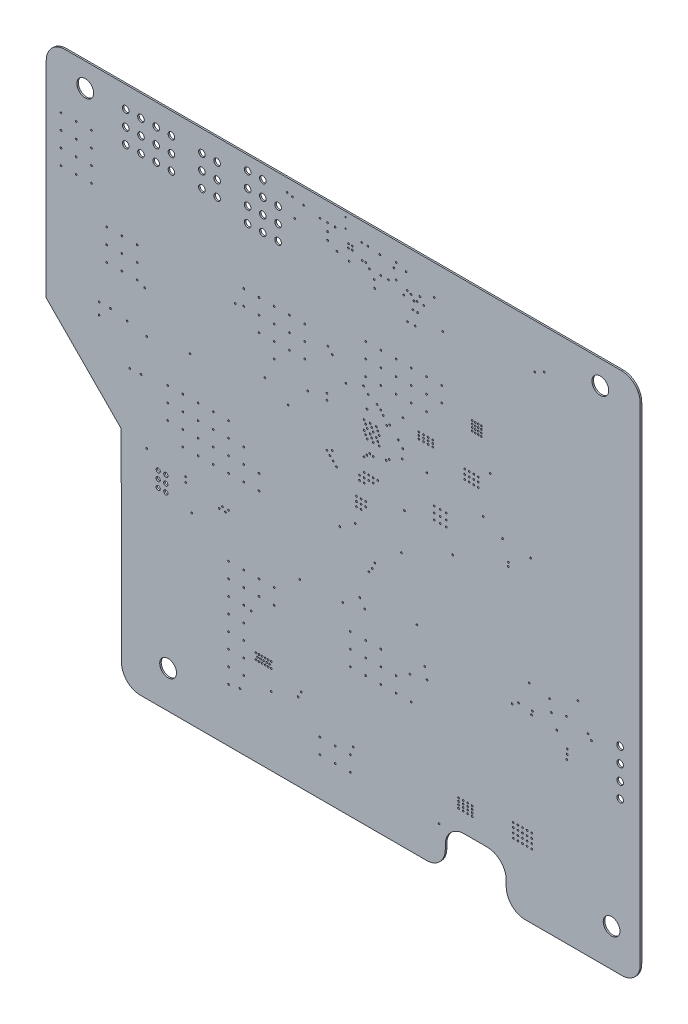
from build123d import *

# Parameters (mm, degrees)
BOARD_OUTLINE_START = 0.034
BOARD_OUTLINE_DEPTH = 0.254
SKETCH2_R           = 0.1395
SKETCH2_R_2         = 0.1015
VIA_DEPTH           = 1.288
SKETCH3_R           = 1.397
NPTH_DEPTH          = 1.288
SKETCH4_R           = 0.55
SKETCH4_R_2         = 0.35
SKETCH4_R_3         = 0.1395
PTH_DEPTH           = 1.288


with BuildPart() as part:
    # Sketch1 → Board_Outline (new body)
    with BuildSketch(Plane.XY.offset(BOARD_OUTLINE_START)):
        with BuildLine():
            Line((48.336, -41.631), (48.336, 39.37))
            ThreePointArc((48.336, 39.37), (47.424377843, 41.607667406), (45.187, 42.52))
            Line((45.187, 42.52), (-47.549, 42.52))
            ThreePointArc((-47.549, 42.52), (-49.791303069, 41.604999919), (-50.724, 39.37))
            Line((-50.724, 39.37), (-50.724, 5.055))
            Line((-50.724, 5.055), (-38.227, -7.569))
            Line((-38.227, -7.569), (-38.176, -41.3))
            ThreePointArc((-38.176, -41.3), (-37.255008626, -43.554008626), (-35.001, -44.475))
            Line((-35.001, -44.475), (12.7, -44.475))
            ThreePointArc((12.7, -44.475), (14.932114941, -43.529199711), (15.824, -41.275))
            Line((15.824, -41.275), (15.824, -40.615))
            ThreePointArc((15.824, -40.615), (16.739034543, -38.423313296), (18.923, -37.49))
            Line((18.923, -37.49), (22.835, -37.49))
            ThreePointArc((22.835, -37.49), (25.048735627, -38.408355043), (25.984, -40.615))
            Line((25.984, -40.615), (25.984, -41.631))
            ThreePointArc((25.984, -41.631), (26.914747345, -43.875252655), (29.159, -44.806))
            Line((29.159, -44.806), (45.11, -44.806))
            ThreePointArc((45.11, -44.806), (47.42069009, -43.927397081), (48.336, -41.631))
        make_face()
    extrude(amount=BOARD_OUTLINE_DEPTH)

    # Sketch2 → Via (cut, through all)
    with BuildSketch(Plane.XY):
        with Locations((-14.249, 11.76)):
            Circle(SKETCH2_R)
        with Locations((-10.388, 9.755)):
            Circle(SKETCH2_R)
        with Locations((-3.912, 13.691)):
            Circle(SKETCH2_R)
        with Locations((-2.311, 4.851)):
            Circle(SKETCH2_R)
        with Locations((-3.912, 14.681)):
            Circle(SKETCH2_R)
        with Locations((-3.912, 6.452)):
            Circle(SKETCH2_R)
        with Locations((-8.433, -14.478)):
            Circle(SKETCH2_R)
        with Locations((39.624, -12.7)):
            Circle(SKETCH2_R)
        with Locations((-7.806, 39.916)):
            Circle(SKETCH2_R)
        with Locations((-27.457, -9.957)):
            Circle(SKETCH2_R)
        with Locations((-27.483, -9.144)):
            Circle(SKETCH2_R)
        with Locations((-26.746, 8.992)):
            Circle(SKETCH2_R)
        with Locations((12.751, 11.532)):
            Circle(SKETCH2_R)
        with Locations((11.1, -11.252)):
            Circle(SKETCH2_R)
        with Locations((3.632, -6.858)):
            Circle(SKETCH2_R)
        with Locations((12.776, -18.364)):
            Circle(SKETCH2_R)
        with Locations((12.395, -16.612)):
            Circle(SKETCH2_R)
        with Locations((4.089, -5.817)):
            Circle(SKETCH2_R)
        with Locations((9.931, -18.974)):
            Circle(SKETCH2_R)
        with Locations((3.099, -7.595)):
            Circle(SKETCH2_R)
        with Locations((-1.753, -3.505)):
            Circle(SKETCH2_R)
        with Locations((-7.137, 13.411)):
            Circle(SKETCH2_R)
        with Locations((5.486, 16.18)):
            Circle(SKETCH2_R)
        with Locations((25.375, 8.357)):
            Circle(SKETCH2_R)
        with Locations((5.08, 16.764)):
            Circle(SKETCH2_R)
        with Locations((26.365, 5.41)):
            Circle(SKETCH2_R)
        with Locations((22.149, 9.931)):
            Circle(SKETCH2_R)
        with Locations((6.045, 15.011)):
            Circle(SKETCH2_R)
        with Locations((-3.023, 6.883)):
            Circle(SKETCH2_R)
        with Locations((-3.023, 20.701)):
            Circle(SKETCH2_R)
        with Locations((2.184, 18.796)):
            Circle(SKETCH2_R)
        with Locations((8.763, 17.475)):
            Circle(SKETCH2_R)
        with Locations((6.553, 15.367)):
            Circle(SKETCH2_R)
        with Locations((8.001, 13.919)):
            Circle(SKETCH2_R)
        with Locations((4.445, 17.247)):
            Circle(SKETCH2_R)
        with Locations((26.314, 4.775)):
            Circle(SKETCH2_R)
        with Locations((17.069, 1.854)):
            Circle(SKETCH2_R)
        with Locations((8.636, 11.481)):
            Circle(SKETCH2_R)
        with Locations((33.528, -12.7)):
            Circle(SKETCH2_R)
        with Locations((14.783, -38.125)):
            Circle(SKETCH2_R)
        with Locations((-33.964, -8.331)):
            Circle(SKETCH2_R)
        with Locations((-33.964, 7.844)):
            Circle(SKETCH2_R)
        with Locations((-19.177, 20.015)):
            Circle(SKETCH2_R)
        with Locations((-9.296, 37.236)):
            Circle(SKETCH2_R)
        with Locations((15.391, 33.271)):
            Circle(SKETCH2_R)
        with Locations((10.109, 35.972)):
            Circle(SKETCH2_R)
        with Locations((-26.441, -13.868)):
            Circle(SKETCH2_R)
        with Locations((2.972, 17.932)):
            Circle(SKETCH2_R)
        with Locations((23.317, 16.713)):
            Circle(SKETCH2_R)
        with Locations((2.769, 15.748)):
            Circle(SKETCH2_R)
        with Locations((0.813, -1.778)):
            Circle(SKETCH2_R)
        with Locations((30.048, 7.874)):
            Circle(SKETCH2_R)
        with Locations((8.738, 13.005)):
            Circle(SKETCH2_R)
        with Locations((-0.762, 17.704)):
            Circle(SKETCH2_R)
        with Locations((3.81, 9.398)):
            Circle(SKETCH2_R)
        with Locations((9.017, 4.216)):
            Circle(SKETCH2_R)
        with Locations((8.509, -2.134)):
            Circle(SKETCH2_R)
        with Locations((-0.808, 40.012)):
            Circle(SKETCH2_R_2)
        with Locations((-0.808, 41.686)):
            Circle(SKETCH2_R_2)
        with Locations((36.144, -17.424)):
            Circle(SKETCH2_R)
        with Locations((33.223, -10.846)):
            Circle(SKETCH2_R)
        with Locations((36.081, -18.199)):
            Circle(SKETCH2_R)
        with Locations((29.82, -10.287)):
            Circle(SKETCH2_R)
        with Locations((2.388, -13.326)):
            Circle(SKETCH2_R)
        with Locations((1.575, -12.09)):
            Circle(SKETCH2_R)
        with Locations((-36.779, 1.829)):
            Circle(SKETCH2_R)
        with Locations((-37.233, 8.455)):
            Circle(SKETCH2_R)
        with Locations((2.261, 8.585)):
            Circle(SKETCH2_R)
        with Locations((2.743, 9.068)):
            Circle(SKETCH2_R)
        with Locations((3.251, 9.55)):
            Circle(SKETCH2_R)
        with Locations((30.365, -14.06)):
            Circle(SKETCH2_R)
        with Locations((28.042, -14.06)):
            Circle(SKETCH2_R)
        with Locations((30.201, -14.707)):
            Circle(SKETCH2_R)
        with Locations((26.975, -14.707)):
            Circle(SKETCH2_R)
        with Locations((37.948, -8.788)):
            Circle(SKETCH2_R)
        with Locations((36.195, -16.637)):
            Circle(SKETCH2_R)
        with Locations((34.417, -14.808)):
            Circle(SKETCH2_R)
        with Locations((-8.179, -30.607)):
            Circle(SKETCH2_R)
        with Locations((-18.415, -35.204)):
            Circle(SKETCH2_R)
        with Locations((-1.27, -14.224)):
            Circle(SKETCH2_R)
        with Locations((-16.561, -23.063)):
            Circle(SKETCH2_R)
        with Locations((-8.712, -31.547)):
            Circle(SKETCH2_R)
        with Locations((0.457, -34.214)):
            Circle(SKETCH2_R)
        with Locations((-13.183, -33.02)):
            Circle(SKETCH2_R)
        with Locations((-34.315, 14.732)):
            Circle(SKETCH2_R)
        with Locations((-3.734, 21.565)):
            Circle(SKETCH2_R)
        with Locations((4.039, 33.833)):
            Circle(SKETCH2_R)
        with Locations((9.474, 36.246)):
            Circle(SKETCH2_R)
        with Locations((11.609, 36.424)):
            Circle(SKETCH2_R)
        with Locations((1.981, 36.818)):
            Circle(SKETCH2_R)
        with Locations((-0.212, 35.611)):
            Circle(SKETCH2_R)
        with Locations((-2.235, 36.017)):
            Circle(SKETCH2_R)
        with Locations((7.264, 38.379)):
            Circle(SKETCH2_R)
        with Locations((13.97, 37.465)):
            Circle(SKETCH2_R)
        with Locations((12.243, 35.458)):
            Circle(SKETCH2_R)
        with Locations((11.125, 35.458)):
            Circle(SKETCH2_R)
        with Locations((3.962, 35.077)):
            Circle(SKETCH2_R)
        with Locations((4.927, 39.129)):
            Circle(SKETCH2_R)
        with Locations((1.88, 39.345)):
            Circle(SKETCH2_R)
        with Locations((2.921, 39.345)):
            Circle(SKETCH2_R)
        with Locations((9.296, 38.862)):
            Circle(SKETCH2_R)
        with Locations((36.043, -11.989)):
            Circle(SKETCH2_R)
        with Locations((10.609, 35.281)):
            Circle(SKETCH2_R)
        with Locations((8.89, 35.281)):
            Circle(SKETCH2_R)
        with Locations((5.969, 9.957)):
            Circle(SKETCH2_R)
        with Locations((-10.542, 40.352)):
            Circle(SKETCH2_R)
        with Locations((32.317, 35.873)):
            Circle(SKETCH2_R)
        with Locations((30.74, 35.064)):
            Circle(SKETCH2_R)
        with Locations((6.502, 10.312)):
            Circle(SKETCH2_R)
        with Locations((-9.666, 40.178)):
            Circle(SKETCH2_R)
    extrude(amount=VIA_DEPTH, mode=Mode.SUBTRACT)

    # Sketch3 → NPTH (cut, through all)
    with BuildSketch(Plane.XY):
        with Locations((41.681, 38.583)):
            Circle(SKETCH3_R)
        with Locations((-44.221, 38.583)):
            Circle(SKETCH3_R)
        with Locations((-30.404, -38.252)):
            Circle(SKETCH3_R)
        with Locations((43.561, -38.557)):
            Circle(SKETCH3_R)
    extrude(amount=NPTH_DEPTH, mode=Mode.SUBTRACT)

    # Sketch4 → PTH (cut, through all)
    with BuildSketch(Plane.XY):
        with Locations((-22.225, 33.833)):
            Circle(SKETCH4_R)
        with Locations((-24.765, 33.833)):
            Circle(SKETCH4_R)
        with Locations((-22.225, 36.373)):
            Circle(SKETCH4_R)
        with Locations((-24.765, 36.373)):
            Circle(SKETCH4_R)
        with Locations((-22.225, 38.913)):
            Circle(SKETCH4_R)
        with Locations((-24.765, 38.913)):
            Circle(SKETCH4_R)
        with Locations((-14.605, 32.563)):
            Circle(SKETCH4_R)
        with Locations((-17.145, 32.563)):
            Circle(SKETCH4_R)
        with Locations((-14.605, 35.103)):
            Circle(SKETCH4_R)
        with Locations((-17.145, 35.103)):
            Circle(SKETCH4_R)
        with Locations((-14.605, 37.643)):
            Circle(SKETCH4_R)
        with Locations((-17.145, 37.643)):
            Circle(SKETCH4_R)
        with Locations((-14.605, 40.183)):
            Circle(SKETCH4_R)
        with Locations((-17.145, 40.183)):
            Circle(SKETCH4_R)
        with Locations((-29.845, 38.913)):
            Circle(SKETCH4_R)
        with Locations((-32.385, 38.913)):
            Circle(SKETCH4_R)
        with Locations((-34.925, 38.913)):
            Circle(SKETCH4_R)
        with Locations((-37.465, 38.913)):
            Circle(SKETCH4_R)
        with Locations((-29.845, 36.347)):
            Circle(SKETCH4_R)
        with Locations((-32.385, 36.347)):
            Circle(SKETCH4_R)
        with Locations((-34.925, 36.347)):
            Circle(SKETCH4_R)
        with Locations((-37.465, 36.347)):
            Circle(SKETCH4_R)
        with Locations((-29.845, 33.807)):
            Circle(SKETCH4_R)
        with Locations((-32.385, 33.807)):
            Circle(SKETCH4_R)
        with Locations((-34.925, 33.807)):
            Circle(SKETCH4_R)
        with Locations((-37.465, 33.807)):
            Circle(SKETCH4_R)
        with Locations((44.983, -19.456)):
            Circle(SKETCH4_R)
        with Locations((44.983, -16.916)):
            Circle(SKETCH4_R)
        with Locations((44.983, -14.376)):
            Circle(SKETCH4_R)
        with Locations((44.983, -11.836)):
            Circle(SKETCH4_R)
        with Locations((-30.785, -13.056)):
            Circle(SKETCH4_R_2)
        with Locations((-30.785, -11.786)):
            Circle(SKETCH4_R_2)
        with Locations((-30.785, -10.516)):
            Circle(SKETCH4_R_2)
        with Locations((-32.055, -13.056)):
            Circle(SKETCH4_R_2)
        with Locations((-32.055, -11.786)):
            Circle(SKETCH4_R_2)
        with Locations((-32.055, -10.516)):
            Circle(SKETCH4_R_2)
        with Locations((-12.065, 32.563)):
            Circle(SKETCH4_R)
        with Locations((-12.065, 35.103)):
            Circle(SKETCH4_R)
        with Locations((-12.065, 37.643)):
            Circle(SKETCH4_R)
        with Locations((1.016, 2.286)):
            Circle(SKETCH4_R_3)
        with Locations((1.778, 2.286)):
            Circle(SKETCH4_R_3)
        with Locations((1.778, 1.524)):
            Circle(SKETCH4_R_3)
        with Locations((1.016, 1.524)):
            Circle(SKETCH4_R_3)
        with Locations((1.016, 0.762)):
            Circle(SKETCH4_R_3)
        with Locations((1.778, 0.762)):
            Circle(SKETCH4_R_3)
        with Locations((2.54, 2.286)):
            Circle(SKETCH4_R_3)
        with Locations((2.54, 1.524)):
            Circle(SKETCH4_R_3)
        with Locations((13.97, 7.366)):
            Circle(SKETCH4_R_3)
        with Locations((14.986, 7.366)):
            Circle(SKETCH4_R_3)
        with Locations((16.002, 7.366)):
            Circle(SKETCH4_R_3)
        with Locations((16.002, 6.35)):
            Circle(SKETCH4_R_3)
        with Locations((16.002, 5.334)):
            Circle(SKETCH4_R_3)
        with Locations((14.986, 6.35)):
            Circle(SKETCH4_R_3)
        with Locations((13.97, 6.35)):
            Circle(SKETCH4_R_3)
        with Locations((13.97, 5.334)):
            Circle(SKETCH4_R_3)
        with Locations((14.986, 5.334)):
            Circle(SKETCH4_R_3)
        with Locations((2.286, 13.97)):
            Circle(SKETCH4_R_3)
        with Locations((3.302, 13.97)):
            Circle(SKETCH4_R_3)
        with Locations((2.794, 12.954)):
            Circle(SKETCH4_R_3)
        with Locations((3.81, 12.954)):
            Circle(SKETCH4_R_3)
        with Locations((4.318, 13.97)):
            Circle(SKETCH4_R_3)
        with Locations((4.826, 12.954)):
            Circle(SKETCH4_R_3)
        with Locations((2.54, 13.462)):
            Circle(SKETCH4_R_3)
        with Locations((3.556, 13.462)):
            Circle(SKETCH4_R_3)
        with Locations((2.286, 12.446)):
            Circle(SKETCH4_R_3)
        with Locations((2.54, 11.938)):
            Circle(SKETCH4_R_3)
        with Locations((4.572, 13.462)):
            Circle(SKETCH4_R_3)
        with Locations((2.794, 11.43)):
            Circle(SKETCH4_R_3)
        with Locations((3.302, 12.446)):
            Circle(SKETCH4_R_3)
        with Locations((3.556, 11.938)):
            Circle(SKETCH4_R_3)
        with Locations((3.81, 11.43)):
            Circle(SKETCH4_R_3)
        with Locations((4.318, 12.446)):
            Circle(SKETCH4_R_3)
        with Locations((4.572, 11.938)):
            Circle(SKETCH4_R_3)
        with Locations((4.826, 11.43)):
            Circle(SKETCH4_R_3)
        with Locations((4.572, 6.35)):
            Circle(SKETCH4_R_3)
        with Locations((2.286, 6.35)):
            Circle(SKETCH4_R_3)
        with Locations((3.048, 6.35)):
            Circle(SKETCH4_R_3)
        with Locations((3.81, 6.35)):
            Circle(SKETCH4_R_3)
        with Locations((2.286, 5.588)):
            Circle(SKETCH4_R_3)
        with Locations((3.048, 5.588)):
            Circle(SKETCH4_R_3)
        with Locations((2.286, 4.826)):
            Circle(SKETCH4_R_3)
        with Locations((1.524, 5.588)):
            Circle(SKETCH4_R_3)
        with Locations((1.524, 4.826)):
            Circle(SKETCH4_R_3)
        with Locations((3.81, 5.588)):
            Circle(SKETCH4_R_3)
        with Locations((-15.748, -28.702)):
            Circle(SKETCH4_R_3)
        with Locations((-15.24, -28.702)):
            Circle(SKETCH4_R_3)
        with Locations((-14.732, -28.702)):
            Circle(SKETCH4_R_3)
        with Locations((-14.224, -28.702)):
            Circle(SKETCH4_R_3)
        with Locations((-13.716, -28.702)):
            Circle(SKETCH4_R_3)
        with Locations((-13.208, -28.702)):
            Circle(SKETCH4_R_3)
        with Locations((-15.494, -29.21)):
            Circle(SKETCH4_R_3)
        with Locations((-14.986, -29.21)):
            Circle(SKETCH4_R_3)
        with Locations((-14.478, -29.21)):
            Circle(SKETCH4_R_3)
        with Locations((-13.97, -29.21)):
            Circle(SKETCH4_R_3)
        with Locations((-13.462, -29.21)):
            Circle(SKETCH4_R_3)
        with Locations((-15.24, -29.718)):
            Circle(SKETCH4_R_3)
        with Locations((-14.732, -29.718)):
            Circle(SKETCH4_R_3)
        with Locations((-14.224, -29.718)):
            Circle(SKETCH4_R_3)
        with Locations((-13.716, -29.718)):
            Circle(SKETCH4_R_3)
        with Locations((-13.208, -29.718)):
            Circle(SKETCH4_R_3)
        with Locations((-15.748, -29.718)):
            Circle(SKETCH4_R_3)
        with Locations((-3.912, 14.681)):
            Circle(SKETCH4_R_3)
        with Locations((-2.87, 5.41)):
            Circle(SKETCH4_R_3)
        with Locations((-3.404, 5.944)):
            Circle(SKETCH4_R_3)
        with Locations((-30.48, 2.54)):
            Circle(SKETCH4_R_3)
        with Locations((20.32, 22.86)):
            Circle(SKETCH4_R_3)
        with Locations((20.32, 22.352)):
            Circle(SKETCH4_R_3)
        with Locations((20.32, 21.844)):
            Circle(SKETCH4_R_3)
        with Locations((20.32, 21.336)):
            Circle(SKETCH4_R_3)
        with Locations((20.828, 22.86)):
            Circle(SKETCH4_R_3)
        with Locations((20.828, 22.352)):
            Circle(SKETCH4_R_3)
        with Locations((20.828, 21.844)):
            Circle(SKETCH4_R_3)
        with Locations((20.828, 21.336)):
            Circle(SKETCH4_R_3)
        with Locations((21.336, 22.86)):
            Circle(SKETCH4_R_3)
        with Locations((21.336, 22.352)):
            Circle(SKETCH4_R_3)
        with Locations((21.336, 21.844)):
            Circle(SKETCH4_R_3)
        with Locations((21.336, 21.336)):
            Circle(SKETCH4_R_3)
        with Locations((21.844, 22.86)):
            Circle(SKETCH4_R_3)
        with Locations((21.844, 22.352)):
            Circle(SKETCH4_R_3)
        with Locations((21.844, 21.844)):
            Circle(SKETCH4_R_3)
        with Locations((21.844, 21.336)):
            Circle(SKETCH4_R_3)
        with Locations((18.034, -32.766)):
            Circle(SKETCH4_R_3)
        with Locations((18.796, -32.766)):
            Circle(SKETCH4_R_3)
        with Locations((19.558, -32.766)):
            Circle(SKETCH4_R_3)
        with Locations((20.32, -32.766)):
            Circle(SKETCH4_R_3)
        with Locations((20.32, -33.274)):
            Circle(SKETCH4_R_3)
        with Locations((19.558, -33.274)):
            Circle(SKETCH4_R_3)
        with Locations((18.796, -33.274)):
            Circle(SKETCH4_R_3)
        with Locations((18.034, -33.274)):
            Circle(SKETCH4_R_3)
        with Locations((18.034, -33.782)):
            Circle(SKETCH4_R_3)
        with Locations((18.796, -33.782)):
            Circle(SKETCH4_R_3)
        with Locations((19.558, -33.782)):
            Circle(SKETCH4_R_3)
        with Locations((20.32, -33.782)):
            Circle(SKETCH4_R_3)
        with Locations((20.32, -34.29)):
            Circle(SKETCH4_R_3)
        with Locations((19.558, -34.29)):
            Circle(SKETCH4_R_3)
        with Locations((18.796, -34.29)):
            Circle(SKETCH4_R_3)
        with Locations((18.034, -34.29)):
            Circle(SKETCH4_R_3)
        with Locations((27.178, -31.75)):
            Circle(SKETCH4_R_3)
        with Locations((27.94, -31.75)):
            Circle(SKETCH4_R_3)
        with Locations((28.702, -31.75)):
            Circle(SKETCH4_R_3)
        with Locations((29.464, -31.75)):
            Circle(SKETCH4_R_3)
        with Locations((30.226, -31.75)):
            Circle(SKETCH4_R_3)
        with Locations((29.464, -32.512)):
            Circle(SKETCH4_R_3)
        with Locations((30.226, -32.512)):
            Circle(SKETCH4_R_3)
        with Locations((28.702, -32.512)):
            Circle(SKETCH4_R_3)
        with Locations((27.94, -32.512)):
            Circle(SKETCH4_R_3)
        with Locations((27.178, -32.512)):
            Circle(SKETCH4_R_3)
        with Locations((27.178, -33.274)):
            Circle(SKETCH4_R_3)
        with Locations((27.94, -33.274)):
            Circle(SKETCH4_R_3)
        with Locations((28.702, -33.274)):
            Circle(SKETCH4_R_3)
        with Locations((29.464, -33.274)):
            Circle(SKETCH4_R_3)
        with Locations((30.226, -33.274)):
            Circle(SKETCH4_R_3)
        with Locations((30.226, -34.036)):
            Circle(SKETCH4_R_3)
        with Locations((29.464, -34.036)):
            Circle(SKETCH4_R_3)
        with Locations((28.702, -34.036)):
            Circle(SKETCH4_R_3)
        with Locations((27.94, -34.036)):
            Circle(SKETCH4_R_3)
        with Locations((27.178, -34.036)):
            Circle(SKETCH4_R_3)
        with Locations((11.43, 16.764)):
            Circle(SKETCH4_R_3)
        with Locations((12.192, 16.764)):
            Circle(SKETCH4_R_3)
        with Locations((12.954, 16.764)):
            Circle(SKETCH4_R_3)
        with Locations((13.716, 16.764)):
            Circle(SKETCH4_R_3)
        with Locations((11.43, 16.256)):
            Circle(SKETCH4_R_3)
        with Locations((12.192, 16.256)):
            Circle(SKETCH4_R_3)
        with Locations((12.954, 16.256)):
            Circle(SKETCH4_R_3)
        with Locations((13.716, 16.256)):
            Circle(SKETCH4_R_3)
        with Locations((13.716, 15.748)):
            Circle(SKETCH4_R_3)
        with Locations((12.954, 15.748)):
            Circle(SKETCH4_R_3)
        with Locations((12.192, 15.748)):
            Circle(SKETCH4_R_3)
        with Locations((11.43, 15.748)):
            Circle(SKETCH4_R_3)
        with Locations((-21.336, -10.414)):
            Circle(SKETCH4_R_3)
        with Locations((-20.32, -10.414)):
            Circle(SKETCH4_R_3)
        with Locations((-20.828, -10.922)):
            Circle(SKETCH4_R_3)
        with Locations((-21.844, -10.922)):
            Circle(SKETCH4_R_3)
        with Locations((-20.32, -17.78)):
            Circle(SKETCH4_R_3)
        with Locations((-17.78, -17.78)):
            Circle(SKETCH4_R_3)
        with Locations((-15.24, -17.78)):
            Circle(SKETCH4_R_3)
        with Locations((-12.7, -17.78)):
            Circle(SKETCH4_R_3)
        with Locations((-12.7, -20.32)):
            Circle(SKETCH4_R_3)
        with Locations((-15.24, -20.32)):
            Circle(SKETCH4_R_3)
        with Locations((-17.78, -20.32)):
            Circle(SKETCH4_R_3)
        with Locations((-20.32, -20.32)):
            Circle(SKETCH4_R_3)
        with Locations((-20.32, -22.86)):
            Circle(SKETCH4_R_3)
        with Locations((-17.78, -22.86)):
            Circle(SKETCH4_R_3)
        with Locations((-17.78, -25.4)):
            Circle(SKETCH4_R_3)
        with Locations((-20.32, -25.4)):
            Circle(SKETCH4_R_3)
        with Locations((-17.78, -27.94)):
            Circle(SKETCH4_R_3)
        with Locations((-20.32, -27.94)):
            Circle(SKETCH4_R_3)
        with Locations((-17.78, -30.48)):
            Circle(SKETCH4_R_3)
        with Locations((-20.32, -30.48)):
            Circle(SKETCH4_R_3)
        with Locations((-17.78, -33.02)):
            Circle(SKETCH4_R_3)
        with Locations((-20.32, -33.02)):
            Circle(SKETCH4_R_3)
        with Locations((-20.32, -35.56)):
            Circle(SKETCH4_R_3)
        with Locations((0, -17.78)):
            Circle(SKETCH4_R_3)
        with Locations((2.54, -17.78)):
            Circle(SKETCH4_R_3)
        with Locations((5.08, -17.78)):
            Circle(SKETCH4_R_3)
        with Locations((5.08, -20.32)):
            Circle(SKETCH4_R_3)
        with Locations((2.54, -20.32)):
            Circle(SKETCH4_R_3)
        with Locations((0, -20.32)):
            Circle(SKETCH4_R_3)
        with Locations((0, -22.86)):
            Circle(SKETCH4_R_3)
        with Locations((2.54, -22.86)):
            Circle(SKETCH4_R_3)
        with Locations((5.08, -22.86)):
            Circle(SKETCH4_R_3)
        with Locations((7.62, -22.86)):
            Circle(SKETCH4_R_3)
        with Locations((7.62, -20.32)):
            Circle(SKETCH4_R_3)
        with Locations((10.16, -22.86)):
            Circle(SKETCH4_R_3)
        with Locations((0, -38.1)):
            Circle(SKETCH4_R_3)
        with Locations((-2.54, -38.1)):
            Circle(SKETCH4_R_3)
        with Locations((-5.08, -38.1)):
            Circle(SKETCH4_R_3)
        with Locations((-5.08, -35.56)):
            Circle(SKETCH4_R_3)
        with Locations((-2.54, -35.56)):
            Circle(SKETCH4_R_3)
        with Locations((0, -35.56)):
            Circle(SKETCH4_R_3)
        with Locations((2.54, 20.32)):
            Circle(SKETCH4_R_3)
        with Locations((-15.24, 17.78)):
            Circle(SKETCH4_R_3)
        with Locations((19.05, 15.24)):
            Circle(SKETCH4_R_3)
        with Locations((19.05, 14.478)):
            Circle(SKETCH4_R_3)
        with Locations((19.05, 13.716)):
            Circle(SKETCH4_R_3)
        with Locations((19.812, 13.716)):
            Circle(SKETCH4_R_3)
        with Locations((19.812, 14.478)):
            Circle(SKETCH4_R_3)
        with Locations((19.812, 15.24)):
            Circle(SKETCH4_R_3)
        with Locations((20.574, 15.24)):
            Circle(SKETCH4_R_3)
        with Locations((20.574, 14.478)):
            Circle(SKETCH4_R_3)
        with Locations((20.574, 13.716)):
            Circle(SKETCH4_R_3)
        with Locations((21.336, 13.716)):
            Circle(SKETCH4_R_3)
        with Locations((21.336, 14.478)):
            Circle(SKETCH4_R_3)
        with Locations((21.336, 15.24)):
            Circle(SKETCH4_R_3)
        with Locations((5.08, 20.32)):
            Circle(SKETCH4_R_3)
        with Locations((7.62, 20.32)):
            Circle(SKETCH4_R_3)
        with Locations((10.16, 20.32)):
            Circle(SKETCH4_R_3)
        with Locations((12.7, 20.32)):
            Circle(SKETCH4_R_3)
        with Locations((2.54, 22.86)):
            Circle(SKETCH4_R_3)
        with Locations((5.08, 22.86)):
            Circle(SKETCH4_R_3)
        with Locations((7.62, 22.86)):
            Circle(SKETCH4_R_3)
        with Locations((10.16, 22.86)):
            Circle(SKETCH4_R_3)
        with Locations((12.7, 22.86)):
            Circle(SKETCH4_R_3)
        with Locations((2.54, 25.4)):
            Circle(SKETCH4_R_3)
        with Locations((5.08, 25.4)):
            Circle(SKETCH4_R_3)
        with Locations((7.62, 25.4)):
            Circle(SKETCH4_R_3)
        with Locations((10.16, 25.4)):
            Circle(SKETCH4_R_3)
        with Locations((12.7, 25.4)):
            Circle(SKETCH4_R_3)
        with Locations((15.24, 25.4)):
            Circle(SKETCH4_R_3)
        with Locations((15.24, 22.86)):
            Circle(SKETCH4_R_3)
        with Locations((-15.24, 20.32)):
            Circle(SKETCH4_R_3)
        with Locations((-17.78, 20.32)):
            Circle(SKETCH4_R_3)
        with Locations((-12.7, 17.78)):
            Circle(SKETCH4_R_3)
        with Locations((-12.7, 20.32)):
            Circle(SKETCH4_R_3)
        with Locations((-12.7, 15.24)):
            Circle(SKETCH4_R_3)
        with Locations((-10.16, 17.78)):
            Circle(SKETCH4_R_3)
        with Locations((-10.16, 20.32)):
            Circle(SKETCH4_R_3)
        with Locations((-7.62, 17.78)):
            Circle(SKETCH4_R_3)
        with Locations((-7.62, 20.32)):
            Circle(SKETCH4_R_3)
        with Locations((-17.78, 22.86)):
            Circle(SKETCH4_R_3)
        with Locations((-15.24, 22.86)):
            Circle(SKETCH4_R_3)
        with Locations((-12.7, 22.86)):
            Circle(SKETCH4_R_3)
        with Locations((-10.16, 22.86)):
            Circle(SKETCH4_R_3)
        with Locations((-7.62, 22.86)):
            Circle(SKETCH4_R_3)
        with Locations((-43.18, 25.4)):
            Circle(SKETCH4_R_3)
        with Locations((-45.72, 25.4)):
            Circle(SKETCH4_R_3)
        with Locations((-48.26, 25.4)):
            Circle(SKETCH4_R_3)
        with Locations((-48.26, 27.94)):
            Circle(SKETCH4_R_3)
        with Locations((-45.72, 27.94)):
            Circle(SKETCH4_R_3)
        with Locations((-43.18, 27.94)):
            Circle(SKETCH4_R_3)
        with Locations((-43.18, 30.48)):
            Circle(SKETCH4_R_3)
        with Locations((-45.72, 30.48)):
            Circle(SKETCH4_R_3)
        with Locations((-48.26, 30.48)):
            Circle(SKETCH4_R_3)
        with Locations((-48.26, 33.02)):
            Circle(SKETCH4_R_3)
        with Locations((-45.72, 33.02)):
            Circle(SKETCH4_R_3)
        with Locations((-43.18, 33.02)):
            Circle(SKETCH4_R_3)
        with Locations((-27.94, 2.54)):
            Circle(SKETCH4_R_3)
        with Locations((-25.4, 2.54)):
            Circle(SKETCH4_R_3)
        with Locations((-22.86, 2.54)):
            Circle(SKETCH4_R_3)
        with Locations((-20.32, 2.54)):
            Circle(SKETCH4_R_3)
        with Locations((-30.48, 0)):
            Circle(SKETCH4_R_3)
        with Locations((-27.94, 0)):
            Circle(SKETCH4_R_3)
        with Locations((-25.4, 0)):
            Circle(SKETCH4_R_3)
        with Locations((-22.86, 0)):
            Circle(SKETCH4_R_3)
        with Locations((-20.32, 0)):
            Circle(SKETCH4_R_3)
        with Locations((-17.78, 0)):
            Circle(SKETCH4_R_3)
        with Locations((-17.78, -2.54)):
            Circle(SKETCH4_R_3)
        with Locations((-20.32, -2.54)):
            Circle(SKETCH4_R_3)
        with Locations((-22.86, -2.54)):
            Circle(SKETCH4_R_3)
        with Locations((-25.4, -2.54)):
            Circle(SKETCH4_R_3)
        with Locations((-27.94, -2.54)):
            Circle(SKETCH4_R_3)
        with Locations((-30.48, -2.54)):
            Circle(SKETCH4_R_3)
        with Locations((-27.94, -5.08)):
            Circle(SKETCH4_R_3)
        with Locations((-25.4, -5.08)):
            Circle(SKETCH4_R_3)
        with Locations((-22.86, -5.08)):
            Circle(SKETCH4_R_3)
        with Locations((-20.32, -5.08)):
            Circle(SKETCH4_R_3)
        with Locations((-17.78, -5.08)):
            Circle(SKETCH4_R_3)
        with Locations((-15.24, -5.08)):
            Circle(SKETCH4_R_3)
        with Locations((-15.24, -2.54)):
            Circle(SKETCH4_R_3)
        with Locations((-40.64, 20.32)):
            Circle(SKETCH4_R_3)
        with Locations((-38.1, 20.32)):
            Circle(SKETCH4_R_3)
        with Locations((-35.56, 20.32)):
            Circle(SKETCH4_R_3)
        with Locations((-35.56, 17.78)):
            Circle(SKETCH4_R_3)
        with Locations((-38.1, 17.78)):
            Circle(SKETCH4_R_3)
        with Locations((-40.64, 17.78)):
            Circle(SKETCH4_R_3)
        with Locations((-40.64, 15.24)):
            Circle(SKETCH4_R_3)
        with Locations((-38.1, 15.24)):
            Circle(SKETCH4_R_3)
        with Locations((-35.56, 15.24)):
            Circle(SKETCH4_R_3)
        with Locations((-0.317, 38.1)):
            Circle(SKETCH4_R_3)
        with Locations((0.317, 38.1)):
            Circle(SKETCH4_R_3)
        with Locations((0.317, 37.465)):
            Circle(SKETCH4_R_3)
        with Locations((-0.317, 37.465)):
            Circle(SKETCH4_R_3)
        with Locations((10.439, 33.909)):
            Circle(SKETCH4_R_3)
        with Locations((11.201, 33.909)):
            Circle(SKETCH4_R_3)
        with Locations((10.795, 31.75)):
            Circle(SKETCH4_R_3)
        with Locations((9.525, 31.75)):
            Circle(SKETCH4_R_3)
        with Locations((-2.54, 39.37)):
            Circle(SKETCH4_R_3)
        with Locations((-3.81, 39.37)):
            Circle(SKETCH4_R_3)
        with Locations((-5.08, 39.37)):
            Circle(SKETCH4_R_3)
        with Locations((-3.81, 38.1)):
            Circle(SKETCH4_R_3)
        with Locations((-3.81, 36.83)):
            Circle(SKETCH4_R_3)
        with Locations((3.175, 36.195)):
            Circle(SKETCH4_R_3)
        with Locations((2.54, 36.83)):
            Circle(SKETCH4_R_3)
        with Locations((5.08, 36.195)):
            Circle(SKETCH4_R_3)
        with Locations((6.35, 36.195)):
            Circle(SKETCH4_R_3)
        with Locations((7.62, 36.83)):
            Circle(SKETCH4_R_3)
        with Locations((7.62, 39.37)):
            Circle(SKETCH4_R_3)
        with Locations((-34.925, 1.905)):
            Circle(SKETCH4_R_3)
        with Locations((-41.91, 6.985)):
            Circle(SKETCH4_R_3)
        with Locations((-41.91, 8.89)):
            Circle(SKETCH4_R_3)
        with Locations((-40.005, 8.89)):
            Circle(SKETCH4_R_3)
        with Locations((40.208, -13.411)):
            Circle(SKETCH4_R_3)
    extrude(amount=PTH_DEPTH, mode=Mode.SUBTRACT)


solid = part.part
